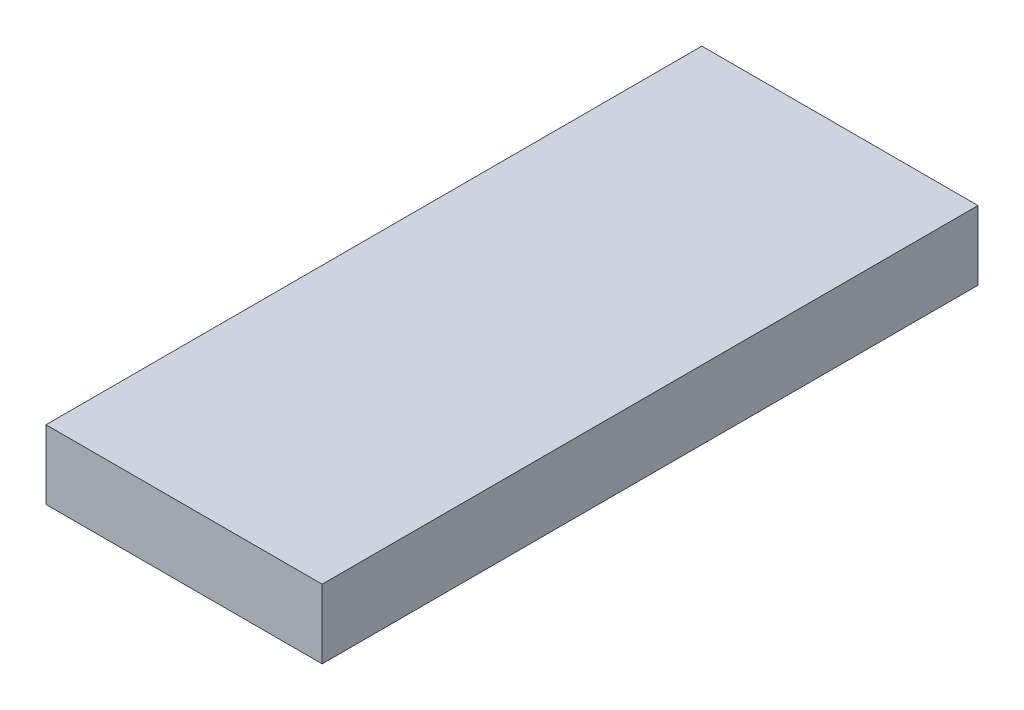
from build123d import *

# Parameters (mm, degrees)
BOSS_EXTRU_1_DEPTH = 19
CHANFREIN1_SIZE    = 1.5


with BuildPart() as part:
    # Esquisse1 → Boss.-Extru.1 (new body)
    with BuildSketch(Plane.XY):
        Polygon((-4, 0), (4, 0), (4, -2), (2.5, -3.5), (-2.5, -3.5), (-4, -2), align=None)
    extrude(amount=BOSS_EXTRU_1_DEPTH)

    # Chanfrein1
    chanfrein1_edges = [part.edges().sort_by_distance(p)[0] for p in [
        (0, -3.5, 0),
        (0, -3.5, 19),
    ]]
    chamfer(chanfrein1_edges, length=CHANFREIN1_SIZE)


solid = part.part
